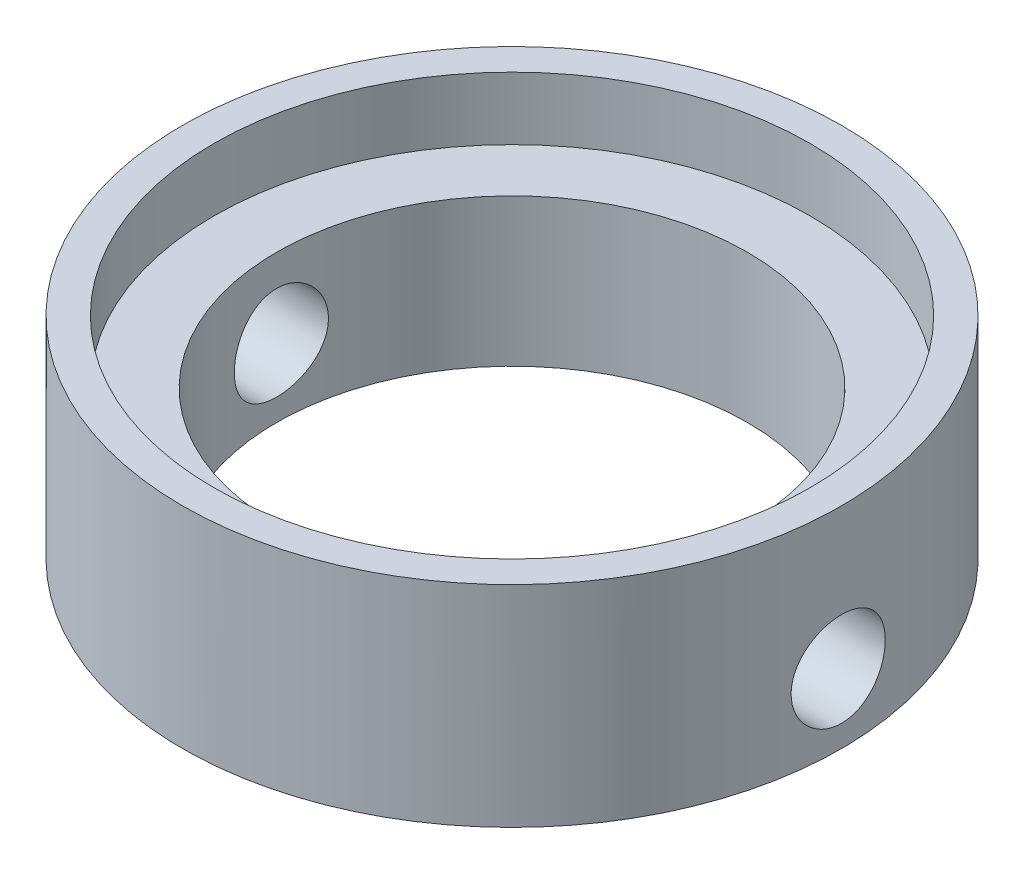
from build123d import *

# Parameters (mm, degrees)
SCHIZZO1_R                    = 10.5
ESTRUSIONE_ESTRUSIONE1_DEPTH  = 7
SCHIZZO2_R                    = 9.5
TAGLIO_ESTRUSIONE1_DEPTH      = 2
SCHIZZO3_R                    = 7.5
TAGLIO_ESTRUSIONE2_DEPTH      = 6
SCHIZZO4_R                    = 1.5
TAGLIO_ESTRUSIONE3_DEPTH      = 11.5
TAGLIO_ESTRUSIONE3_DEPTH_BACK = 11.5
SCHIZZO6_R                    = 10.5
TAGLIO_ESTRUSIONE4_DEPTH      = 0.3


with BuildPart() as part:
    # Schizzo1 → Estrusione-Estrusione1 (new body)
    with BuildSketch(Plane(origin=(0, 0, 0), x_dir=(1, 0, 0), z_dir=(0, 1, 0))):
        Circle(SCHIZZO1_R)
    extrude(amount=ESTRUSIONE_ESTRUSIONE1_DEPTH)

    # Schizzo2 → Taglio-Estrusione1 (cut)
    with BuildSketch(Plane(origin=(0, 7, 0), x_dir=(1, 0, 0), z_dir=(0, 1, 0))):
        Circle(SCHIZZO2_R)
    extrude(amount=-TAGLIO_ESTRUSIONE1_DEPTH, mode=Mode.SUBTRACT)

    # Schizzo3 → Taglio-Estrusione2 (cut, through all)
    with BuildSketch(Plane(origin=(0, 5, 0), x_dir=(1, 0, 0), z_dir=(0, 1, 0))):
        Circle(SCHIZZO3_R)
    extrude(amount=-TAGLIO_ESTRUSIONE2_DEPTH, mode=Mode.SUBTRACT)

    # Schizzo4 → Taglio-Estrusione3 (cut, two sides)
    with BuildSketch(Plane(origin=(0, 0, 0), x_dir=(0, 0, -1), z_dir=(1, 0, 0))) as taglio_estrusione3_sk:
        with Locations((0, 2.5)):
            Circle(SCHIZZO4_R)
    extrude(amount=TAGLIO_ESTRUSIONE3_DEPTH, mode=Mode.SUBTRACT)
    extrude(taglio_estrusione3_sk.sketch, amount=-TAGLIO_ESTRUSIONE3_DEPTH_BACK, mode=Mode.SUBTRACT)

    # Schizzo6 → Taglio-Estrusione4 (cut)
    with BuildSketch(Plane.XZ):
        Circle(SCHIZZO6_R)
    extrude(amount=-TAGLIO_ESTRUSIONE4_DEPTH, mode=Mode.SUBTRACT)


solid = part.part
